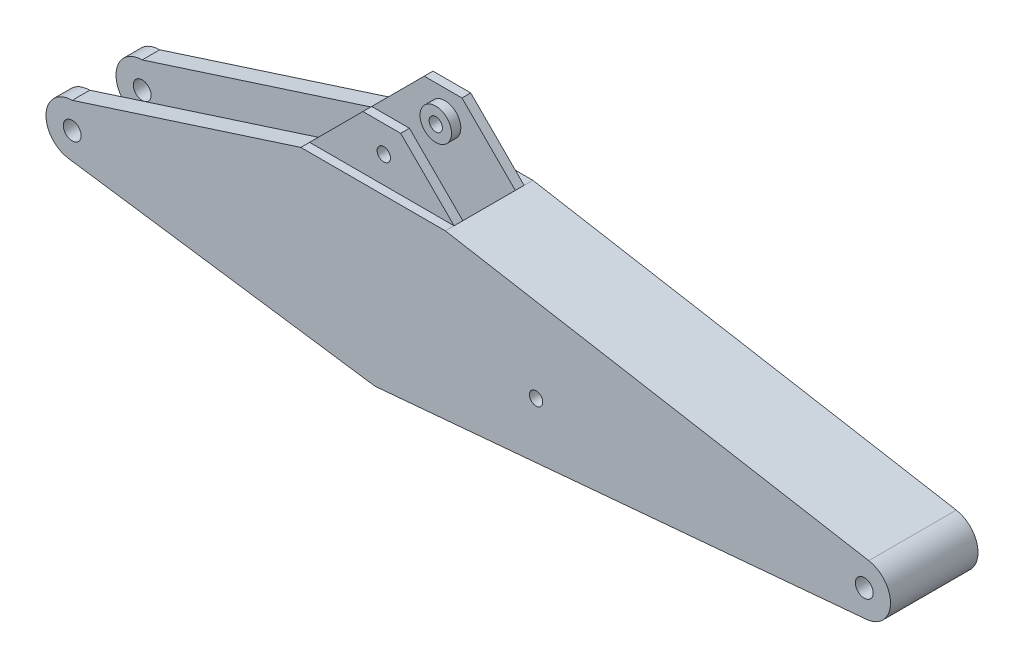
from build123d import *

# Parameters (mm, degrees)
BOSS_EXTRUDE1_START = 150
SKETCH1_R           = 51
SKETCH1_R_2         = 38
BOSS_EXTRUDE1_DEPTH = 100
BOSS_EXTRUDE2_DEPTH = 306
SKETCH4_R           = 90
SKETCH4_R_2         = 38
BOSS_EXTRUDE3_DEPTH = 53
CUT_EXTRUDE1_START  = 250
SKETCH1_3_R         = 38
CUT_EXTRUDE1_DEPTH  = 50
CUT_EXTRUDE2_START  = -250
SKETCH1_5_R         = 38
CUT_EXTRUDE2_DEPTH  = 50


with BuildPart() as part:
    # Sketch1 → Boss-Extrude1 (new body)
    with BuildSketch(Plane.XY.offset(BOSS_EXTRUDE1_START)):
        with BuildLine():
            Line((1730, -400), (4538.33185886, -149.406363785))
            ThreePointArc((4538.33185886, -149.406363785), (4674.868328403, -6.283640799), (4550.791625622, 147.766004371))
            Line((4550.791625622, 147.766004371), (2131.718421044, 570))
            Line((2131.718421044, 570), (1306.022410762, 570))
            Line((1306.022410762, 570), (0, 150))
            ThreePointArc((0, 150), (-149.618651652, 10.689203798), (-21.324056793, -148.476545629))
            Line((-21.324056793, -148.476545629), (1730, -400))
        make_face()
        with Locations((4525, 0)):
            Circle(SKETCH1_R, mode=Mode.SUBTRACT)
        with Locations((2650, 0)):
            Circle(SKETCH1_R_2, mode=Mode.SUBTRACT)
        Circle(SKETCH1_R, mode=Mode.SUBTRACT)
        Polygon((1611.022410762, 875), (1306.022410762, 570), (2131.718421044, 570), (1826.718421044, 875), align=None)
        with Locations((1730, 723)):
            Circle(SKETCH1_R_2, mode=Mode.SUBTRACT)
    boss_extrude1 = extrude(amount=BOSS_EXTRUDE1_DEPTH)

    # Sketch3 → Boss-Extrude2 (add)
    with BuildSketch(Plane(origin=(0, 0, 150), x_dir=(-1, 0, 0), z_dir=(0, 0, -1))):
        with BuildLine():
            Line((-1730, -400), (-4538.33185886, -149.406363785))
            ThreePointArc((-4538.33185886, -149.406363785), (-4674.868328403, -6.283640799), (-4550.791625622, 147.766004371))
            Line((-4550.791625622, 147.766004371), (-2131.718421044, 570))
            Line((-2131.718421044, 570), (-2124.840654212, 530.595732168))
            Line((-2124.840654212, 530.595732168), (-4543.913858789, 108.361736539))
            ThreePointArc((-4543.913858789, 108.361736539), (-4634.903440829, -4.608003253), (-4534.776696497, -109.564666775))
            Line((-4534.776696497, -109.564666775), (-1731.080049821, -359.7446928))
            Line((-1731.080049821, -359.7446928), (-711.686415145, -213.340372387))
            Line((-711.686415145, -213.340372387), (-706, -252.934117888))
            Line((-706, -252.934117888), (-1730, -400))
        make_face()
    extrude(amount=BOSS_EXTRUDE2_DEPTH)

    # Sketch4 → Boss-Extrude3 (add)
    with BuildSketch(Plane(origin=(0, 0, 150), x_dir=(-1, 0, 0), z_dir=(0, 0, -1))):
        with Locations((-2650, 0)):
            Circle(SKETCH4_R)
        with Locations((-2650, 0)):
            Circle(SKETCH4_R_2, mode=Mode.SUBTRACT)
        with Locations((-1730, 723)):
            Circle(SKETCH4_R)
        with Locations((-1730, 723)):
            Circle(SKETCH4_R_2, mode=Mode.SUBTRACT)
    boss_extrude3 = extrude(amount=BOSS_EXTRUDE3_DEPTH)

    # Sketch1_3 → Cut-Extrude1 (cut)
    with BuildSketch(Plane.XY.offset(CUT_EXTRUDE1_START)):
        Polygon((1611.022410762, 875), (1306.022410762, 570), (2131.718421044, 570), (1826.718421044, 875), align=None)
        with Locations((1730, 723)):
            Circle(SKETCH1_3_R, mode=Mode.SUBTRACT)
    extrude(amount=-CUT_EXTRUDE1_DEPTH, mode=Mode.SUBTRACT)

    # Mirror1: Boss-Extrude1, Boss-Extrude3 across plane
    add(boss_extrude1.mirror(Plane.XY))
    add(boss_extrude3.mirror(Plane.XY))

    # Sketch1_5 → Cut-Extrude2 (cut)
    with BuildSketch(Plane.XY.offset(CUT_EXTRUDE2_START)):
        Polygon((1611.022410762, 875), (1306.022410762, 570), (2131.718421044, 570), (1826.718421044, 875), align=None)
        with Locations((1730, 723)):
            Circle(SKETCH1_5_R, mode=Mode.SUBTRACT)
    extrude(amount=CUT_EXTRUDE2_DEPTH, mode=Mode.SUBTRACT)


solid = part.part
